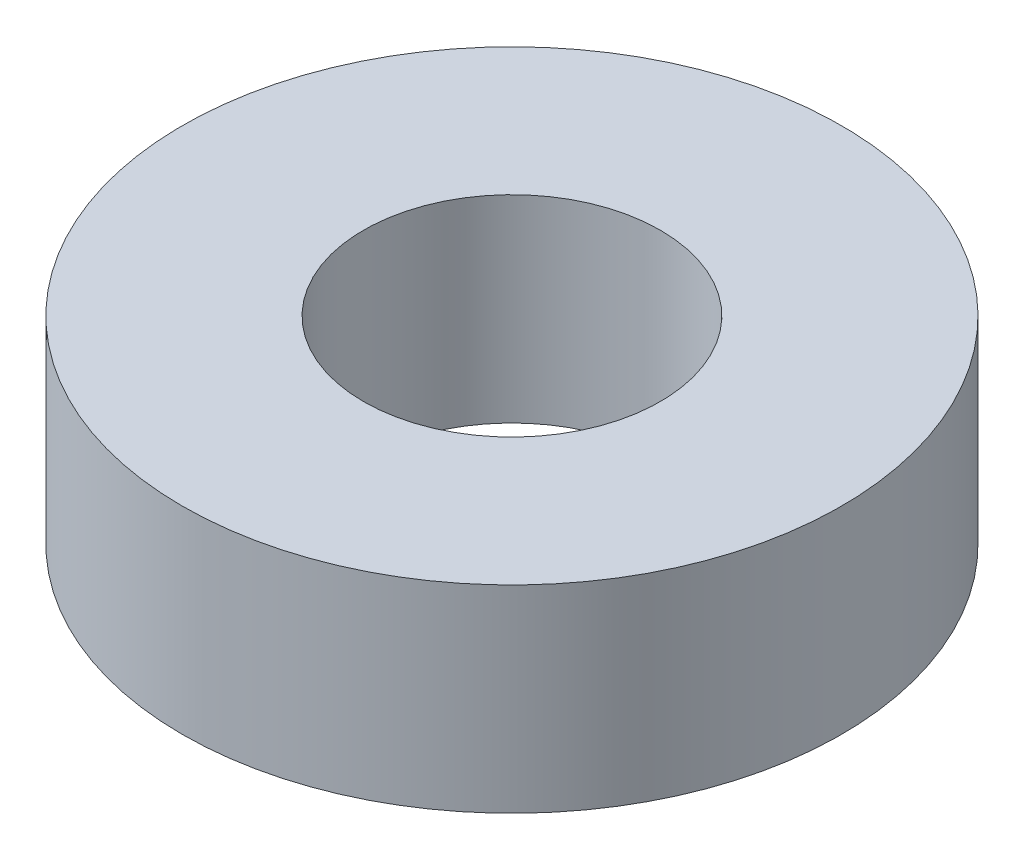
from build123d import *

# Parameters (mm, degrees)
SKETCH1_R               = 7.5
BOSS_EXTRUDE1_DEPTH     = 4.5
F_1_4_CLEARANCE_HOLE1_D = 6.7564


with BuildPart() as part:
    # Sketch1 → Boss-Extrude1 (new body)
    with BuildSketch(Plane(origin=(0, 0, 0), x_dir=(1, 0, 0), z_dir=(0, 1, 0))):
        Circle(SKETCH1_R)
    extrude(amount=BOSS_EXTRUDE1_DEPTH)

    # 1/4 Clearance Hole1 (through all)
    with Locations(Plane(origin=(0, 4.5, 0), x_dir=(1, 0, 0), z_dir=(0, 1, 0))):
        with Locations((0, 0)):
            Hole(F_1_4_CLEARANCE_HOLE1_D / 2)


solid = part.part
